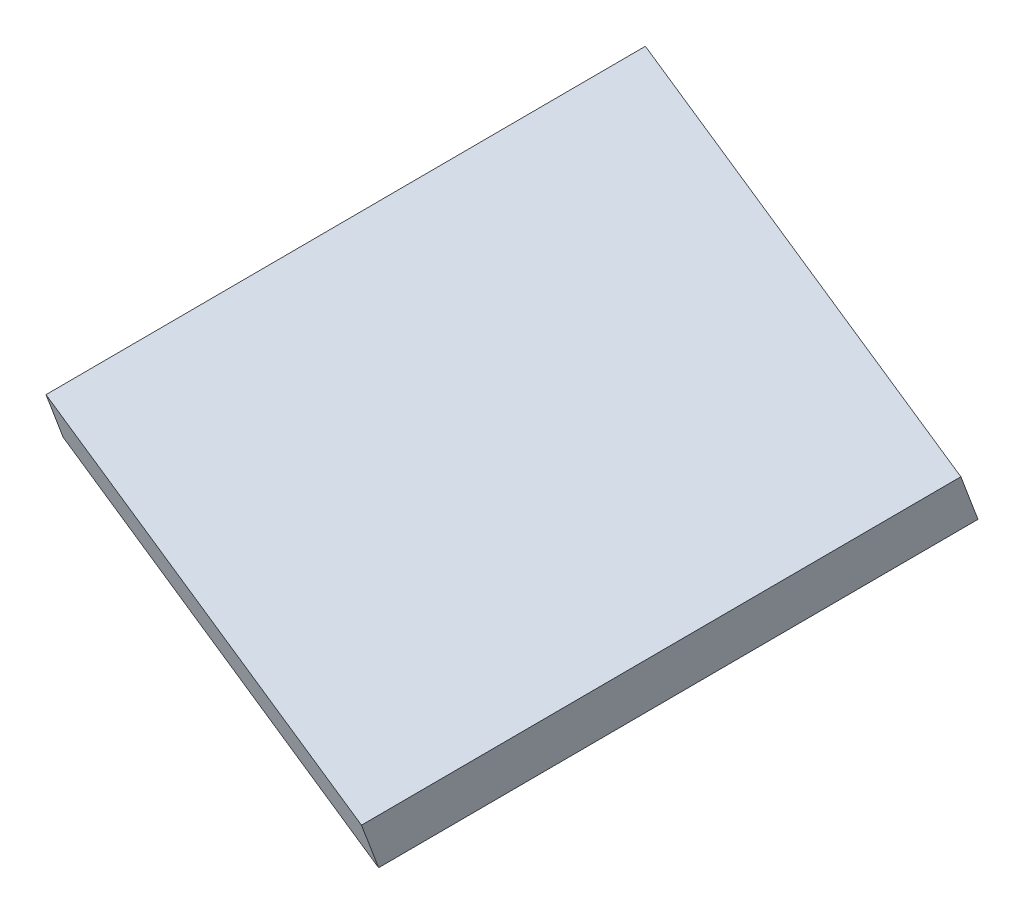
from build123d import *

# Parameters (mm, degrees)
BOSS_EXTRUDE1_DEPTH = 5


with BuildPart() as part:
    # Sketch2 → Boss-Extrude1 (new body)
    with BuildSketch(Plane(origin=(-485.015646161, 24.093142413, 406.723630023), x_dir=(-0.331348583, -0.33551809, 0.881836565), z_dir=(0.012789288, 0.932952563, 0.359772079))):
        Polygon((-264.138639033, 198.849094652), (-264.138639033, 160.980379416), (-264.138639033, 148.849094652), (-314.138639033, 148.849094652), (-314.138639033, 198.849094652), align=None)
    extrude(amount=BOSS_EXTRUDE1_DEPTH)


solid = part.part
